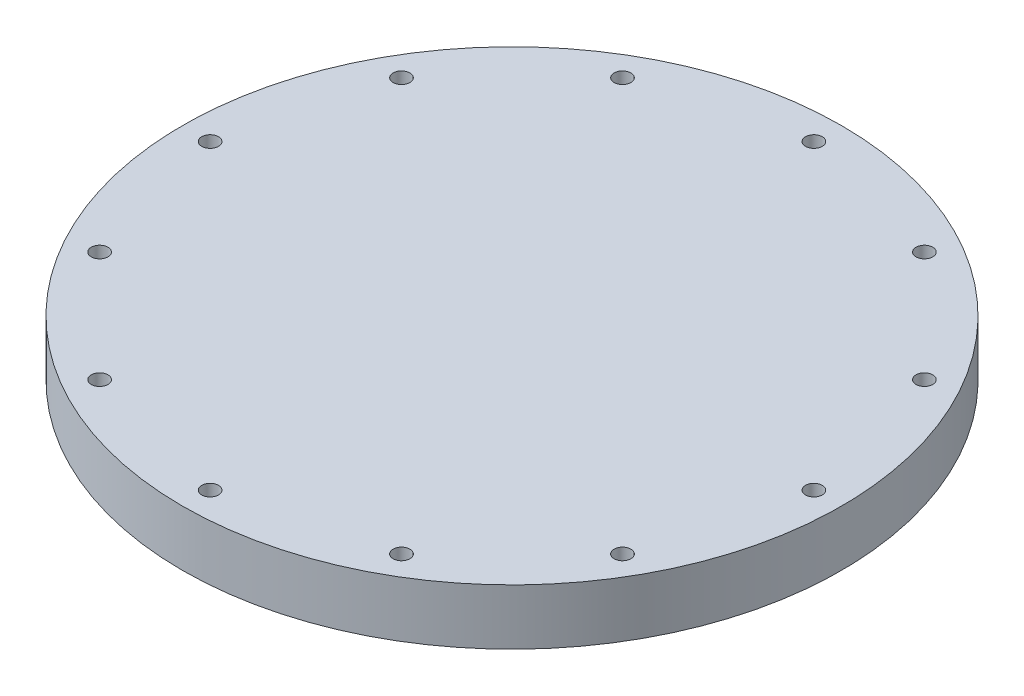
from build123d import *

# Parameters (mm, degrees)
SKETCH2_R           = 25.4
BASE_CYLINDER_DEPTH = 19.05
SKETCH3_R           = 56.35625
AFT_FLANGE_DEPTH    = 9.525
BOLT_CIRCLE_D       = 2.8702
BOLT_CIRCLE_DEPTH   = 9.525
SKETCH20_W          = 71.924294246
SKETCH20_H          = 16.463903039
CUT_EXTRUDE2_DEPTH  = 152.4


with BuildPart() as part:
    # Sketch2 → Base Cylinder (new body)
    with BuildSketch(Plane(origin=(0, 0, 0), x_dir=(1, 0, 0), z_dir=(0, 1, 0))):
        Circle(SKETCH2_R)
    extrude(amount=BASE_CYLINDER_DEPTH)

    # Sketch3 → Aft Flange (add)
    with BuildSketch(Plane.XZ):
        Circle(SKETCH3_R)
    extrude(amount=-AFT_FLANGE_DEPTH)

    # Bolt Circle
    with Locations(Plane(origin=(0, 0, 0), x_dir=(-1, 0, 0), z_dir=(0, -1, 0))):
        with Locations((-25.81275, -44.708994483), (-44.708994483, -25.81275), (-51.6255, 0), (-44.708994483, 25.81275), (-25.81275, 44.708994483), (0, 51.6255), (25.81275, 44.708994483), (44.708994483, 25.81275), (51.6255, 0), (44.708994483, -25.81275), (25.81275, -44.708994483), (0, -51.6255)):
            Hole(BOLT_CIRCLE_D / 2, depth=BOLT_CIRCLE_DEPTH)

    # Sketch20 → Cut-Extrude2 (cut, symmetric)
    with BuildSketch(Plane.XY):
        with Locations((-3.698234988, 17.756951519)):
            Rectangle(SKETCH20_W, SKETCH20_H)
    extrude(amount=CUT_EXTRUDE2_DEPTH, both=True, mode=Mode.SUBTRACT)


solid = part.part
